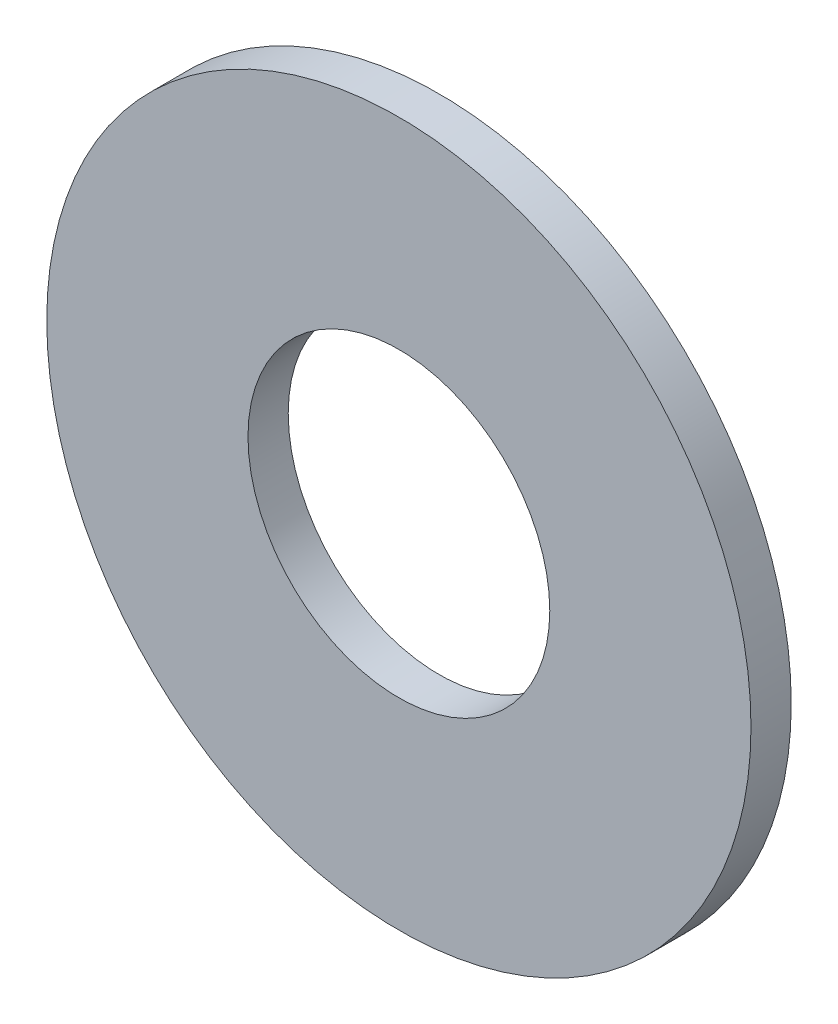
from build123d import *

# Parameters (mm, degrees)
SKETCH1_R           = 17.5
SKETCH1_R_2         = 7.5
BOSS_EXTRUDE1_DEPTH = 2


with BuildPart() as part:
    # Sketch1 → Boss-Extrude1 (new body)
    with BuildSketch(Plane.XY):
        Circle(SKETCH1_R)
        Circle(SKETCH1_R_2, mode=Mode.SUBTRACT)
    extrude(amount=BOSS_EXTRUDE1_DEPTH)


solid = part.part
